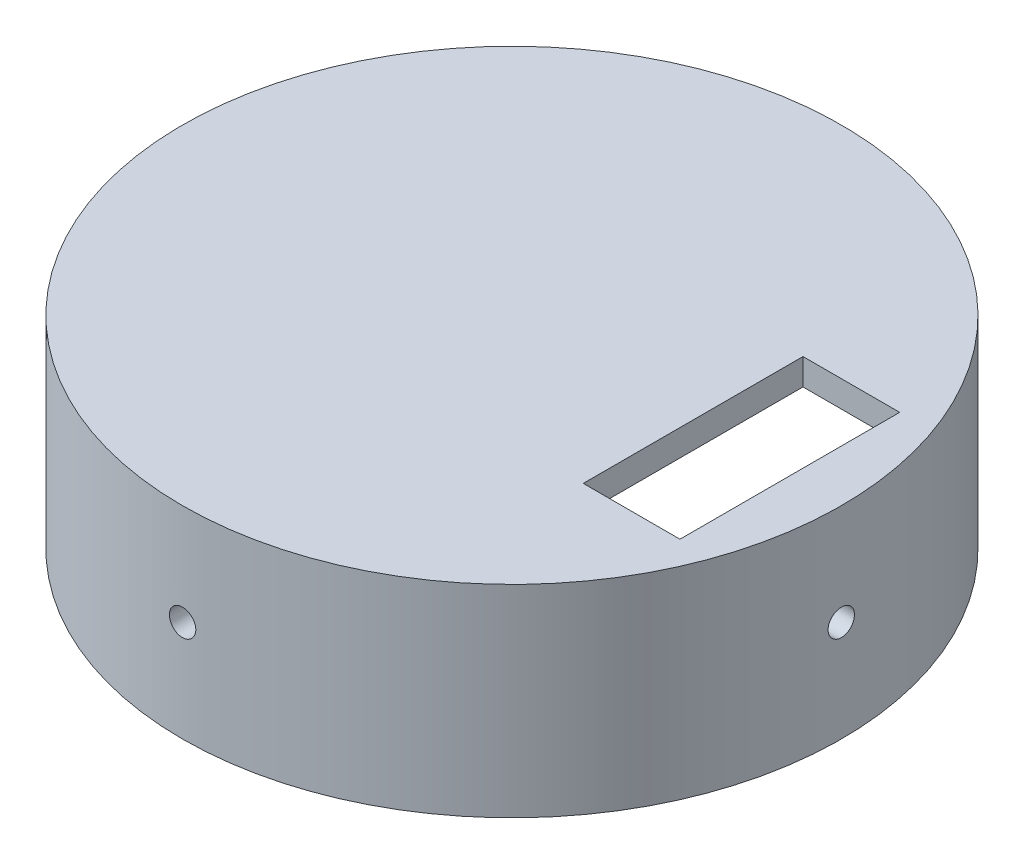
from build123d import *

# Parameters (mm, degrees)
SKETCH1_R               = 37.5
SKETCH1_R_2             = 34
BOSS_EXTRUDE1_DEPTH     = 20
SKETCH2_R               = 37.5
BOSS_EXTRUDE2_DEPTH     = 3
SKETCH3_W               = 11
SKETCH3_H               = 25
CUT_EXTRUDE1_DEPTH      = 3
SKETCH4_R               = 1.5
CUT_EXTRUDE2_DEPTH      = 80
CUT_EXTRUDE2_DEPTH_BACK = 80
SKETCH5_R               = 1.5
CUT_EXTRUDE4_DEPTH      = 80
CUT_EXTRUDE4_DEPTH_BACK = 80


with BuildPart() as part:
    # Sketch1 → Boss-Extrude1 (new body)
    with BuildSketch(Plane(origin=(0, 0, 0), x_dir=(1, 0, 0), z_dir=(0, 1, 0))):
        Circle(SKETCH1_R)
        Circle(SKETCH1_R_2, mode=Mode.SUBTRACT)
    extrude(amount=BOSS_EXTRUDE1_DEPTH)

    # Sketch2 → Boss-Extrude2 (add)
    with BuildSketch(Plane(origin=(0, 20, 0), x_dir=(1, 0, 0), z_dir=(0, 1, 0))):
        Circle(SKETCH2_R)
    extrude(amount=BOSS_EXTRUDE2_DEPTH)

    # Sketch3 → Cut-Extrude1 (cut)
    with BuildSketch(Plane(origin=(0, 23, 0), x_dir=(1, 0, 0), z_dir=(0, 1, 0))):
        with Locations((26.118823508, 0)):
            Rectangle(SKETCH3_W, SKETCH3_H)
    extrude(amount=-CUT_EXTRUDE1_DEPTH, mode=Mode.SUBTRACT)

    # Sketch4 → Cut-Extrude2 (cut, two sides)
    with BuildSketch(Plane.XY) as cut_extrude2_sk:
        with Locations((0, 11.5)):
            Circle(SKETCH4_R)
    extrude(amount=CUT_EXTRUDE2_DEPTH, mode=Mode.SUBTRACT)
    extrude(cut_extrude2_sk.sketch, amount=-CUT_EXTRUDE2_DEPTH_BACK, mode=Mode.SUBTRACT)

    # Sketch5 → Cut-Extrude4 (cut, two sides)
    with BuildSketch(Plane(origin=(0, 0, 0), x_dir=(0, 0, -1), z_dir=(1, 0, 0))) as cut_extrude4_sk:
        with Locations((0, 11.5)):
            Circle(SKETCH5_R)
    extrude(amount=CUT_EXTRUDE4_DEPTH, mode=Mode.SUBTRACT)
    extrude(cut_extrude4_sk.sketch, amount=-CUT_EXTRUDE4_DEPTH_BACK, mode=Mode.SUBTRACT)


solid = part.part
